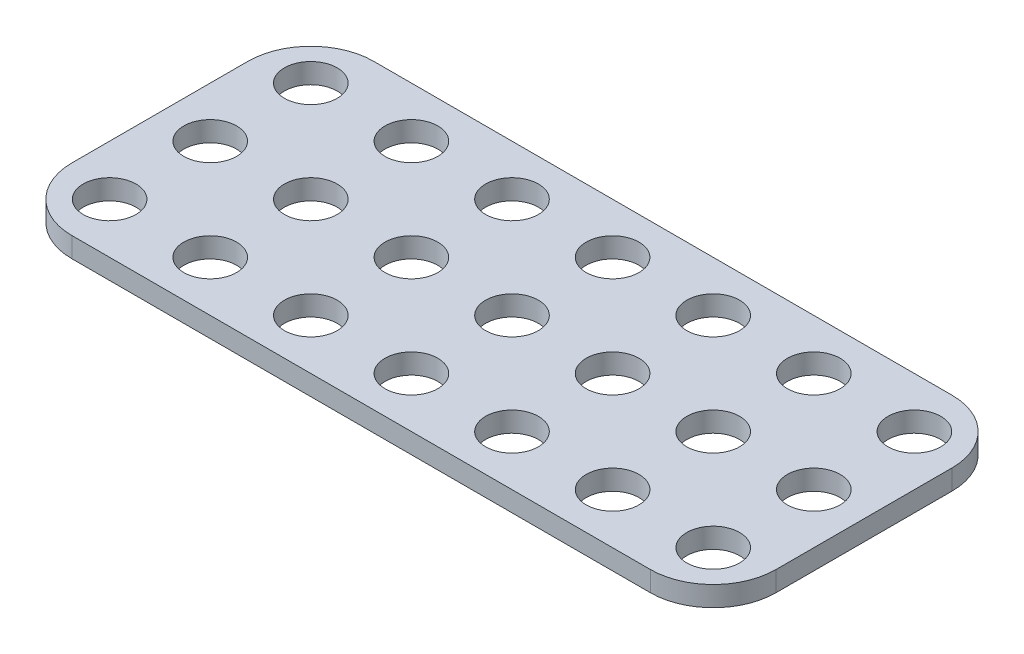
from build123d import *

# Parameters (mm, degrees)
SKETCH1_W            = 56
SKETCH1_H            = 24
BOSS_EXTRUDE1_DEPTH  = 1.6
FILLET1_R            = 5
SKETCH2_R            = 2.1
CUT_EXTRUDE1_DEPTH   = 2.6
LPATTERN1_COUNT      = 7
LPATTERN1_PITCH      = 8
LPATTERN1_COUNT_DIR2 = 3
LPATTERN1_PITCH_DIR2 = 8


with BuildPart() as part:
    # Sketch1 → Boss-Extrude1 (new body)
    with BuildSketch(Plane(origin=(0, 0, 0), x_dir=(1, 0, 0), z_dir=(0, 1, 0))):
        with Locations((28, -12)):
            Rectangle(SKETCH1_W, SKETCH1_H)
    extrude(amount=BOSS_EXTRUDE1_DEPTH)

    # Fillet1
    fillet1_edges = [part.edges().sort_by_distance(p)[0] for p in [
        (0, 0.8, 0),
        (56, 0.8, 0),
        (56, 0.8, 24),
        (0, 0.8, 24),
    ]]
    fillet(fillet1_edges, radius=FILLET1_R)

    # Sketch2 → Cut-Extrude1 (cut, through all)
    with BuildSketch(Plane(origin=(0, 1.6, 0), x_dir=(1, 0, 0), z_dir=(0, 1, 0))):
        with Locations((4, -4)):
            Circle(SKETCH2_R)
    cut_extrude1 = extrude(amount=-CUT_EXTRUDE1_DEPTH, mode=Mode.SUBTRACT)

    # LPattern1: Cut-Extrude1 7 × 3
    with Locations(*[(i * LPATTERN1_PITCH, 0, j * LPATTERN1_PITCH_DIR2) for i in range(LPATTERN1_COUNT) for j in range(LPATTERN1_COUNT_DIR2) if (i, j) != (0, 0)]):
        add(cut_extrude1, mode=Mode.SUBTRACT)


solid = part.part
